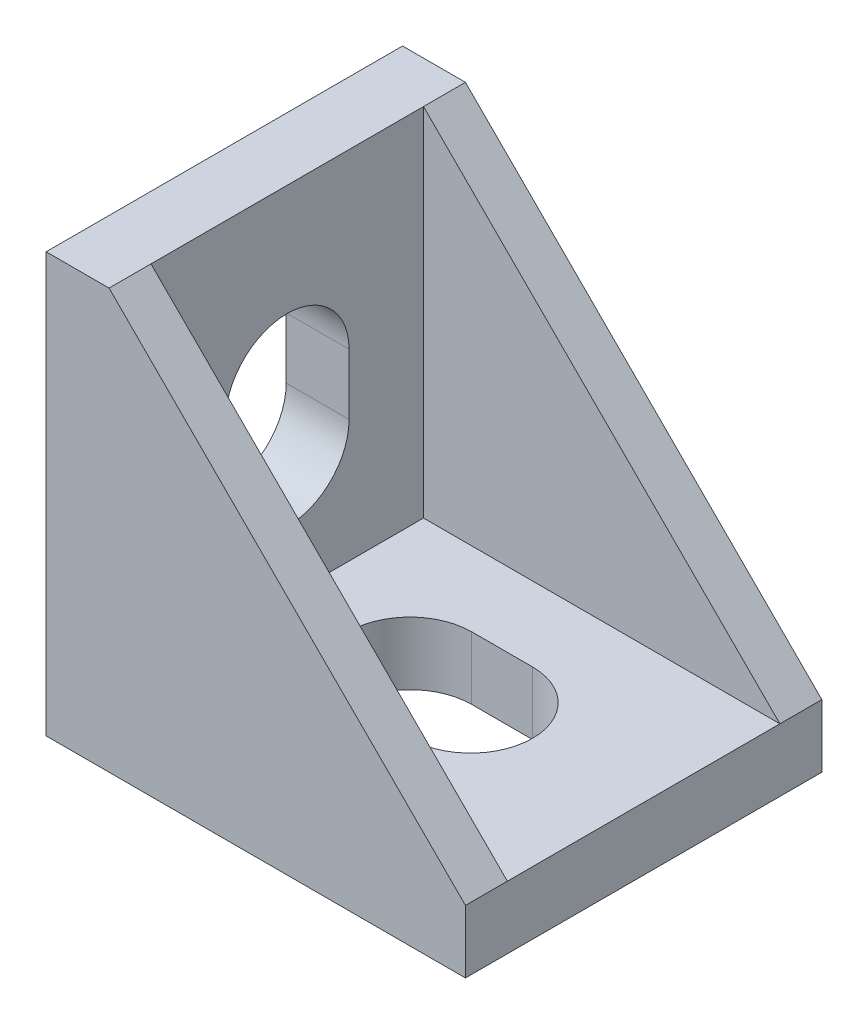
from build123d import *

# Parameters (mm, degrees)
EXTRUDE_1_DEPTH     = 17
SKETCH_2_W          = 17
SKETCH_2_H          = 13
CUT_EXTRUDE_1_DEPTH = 18
CUT_EXTRUDE_2_DEPTH = 4


with BuildPart() as part:
    # 草图1 → 凸台-拉伸1 (new body)
    with BuildSketch(Plane.XY):
        Polygon((0, 0), (20, 0), (20, 3), (3, 20), (0, 20), align=None)
    extrude(amount=EXTRUDE_1_DEPTH)

    # 草图2 → 切除-拉伸1 (cut, through all)
    with BuildSketch(Plane(origin=(0, 3, 0), x_dir=(-1, 0, 0), z_dir=(0, -1, 0))):
        with Locations((-11.5, -8.5)):
            Rectangle(SKETCH_2_W, SKETCH_2_H)
    extrude(amount=-CUT_EXTRUDE_1_DEPTH, mode=Mode.SUBTRACT)

    # 草图5 → 切除-拉伸2 (cut, through all)
    with BuildSketch(Plane(origin=(0, 3, 0), x_dir=(1, 0, 0), z_dir=(0, 1, 0))):
        with BuildLine():
            Line((11.75, -11.45), (8.85, -11.45))
            ThreePointArc((8.85, -11.45), (5.9, -8.5), (8.85, -5.55))
            Line((8.85, -5.55), (11.75, -5.55))
            ThreePointArc((11.75, -5.55), (14.7, -8.5), (11.75, -11.45))
        make_face()
    cut_extrude_2 = extrude(amount=-CUT_EXTRUDE_2_DEPTH, mode=Mode.SUBTRACT)

    # 镜向1: 切除-拉伸2 across plane
    add(cut_extrude_2.mirror(Plane(origin=(0, 0, 0), x_dir=(0, 0, 1), z_dir=(0.707106781, -0.707106781, 0))), mode=Mode.SUBTRACT)


solid = part.part
